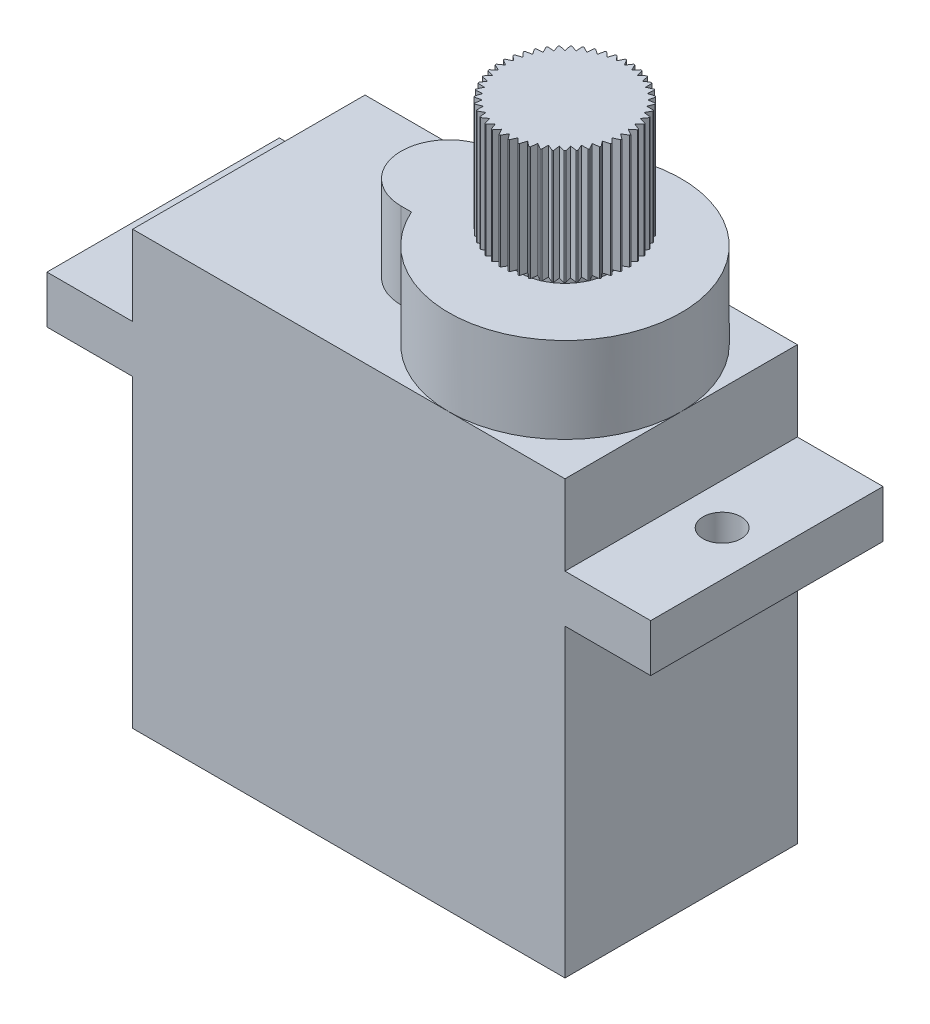
from build123d import *

# Parameters (mm, degrees)
SKETCH2_W                = 22.7
SKETCH2_H                = 12.2
BOSS_EXTRUDE1_DEPTH      = 6.7
BOSS_EXTRUDE1_DEPTH_BACK = 16
SKETCH3_W                = 4.5
SKETCH3_H                = 12.2
SKETCH3_R                = 1
BOSS_EXTRUDE2_DEPTH      = 2.5
BOSS_EXTRUDE3_DEPTH      = 4.5
SKETCH5_R                = 2.425
SKETCH5_R_2              = 0.5
BOSS_EXTRUDE4_DEPTH      = 2.7
BOSS_EXTRUDE5_DEPTH      = 4
BOSS_EXTRUDE5_DEPTH_BACK = 2


with BuildPart() as part:
    # Sketch2 → Boss-Extrude1 (new body, two sides)
    with BuildSketch(Plane(origin=(0, 0, 0), x_dir=(1, 0, 0), z_dir=(0, 1, 0))) as boss_extrude1_sk:
        Rectangle(SKETCH2_W, SKETCH2_H)
    extrude(amount=BOSS_EXTRUDE1_DEPTH)
    extrude(boss_extrude1_sk.sketch, amount=-BOSS_EXTRUDE1_DEPTH_BACK)

    # Sketch3 → Boss-Extrude2 (add)
    with BuildSketch(Plane(origin=(0, 0, 0), x_dir=(1, 0, 0), z_dir=(0, 1, 0))):
        with Locations((13.6, 0)):
            Rectangle(SKETCH3_W, SKETCH3_H)
        with Locations((13.5, 0)):
            Circle(SKETCH3_R, mode=Mode.SUBTRACT)
        with Locations((-13.6, 0)):
            Rectangle(SKETCH3_W, SKETCH3_H)
        with Locations((-13.5, 0)):
            Circle(SKETCH3_R, mode=Mode.SUBTRACT)
    extrude(amount=BOSS_EXTRUDE2_DEPTH)

    # Sketch4 → Boss-Extrude3 (add)
    with BuildSketch(Plane(origin=(0, 6.7, 0), x_dir=(1, 0, 0), z_dir=(0, 1, 0))):
        with BuildLine():
            Line((-0.85, 2.5), (-0.314171097, 2.5))
            ThreePointArc((-0.314171097, 2.5), (11.35, 0), (-0.314171097, -2.5))
            Line((-0.314171097, -2.5), (-0.85, -2.5))
            ThreePointArc((-0.85, -2.5), (-3.35, 0), (-0.85, 2.5))
        make_face()
    extrude(amount=BOSS_EXTRUDE3_DEPTH)


with BuildPart() as body_2:
    # Sketch5 → Boss-Extrude4 (new body)
    with BuildSketch(Plane(origin=(0, 11.2, 0), x_dir=(1, 0, 0), z_dir=(0, 1, 0))):
        with Locations((5.25, 0)):
            Circle(SKETCH5_R)
        with Locations((5.25, 0)):
            Circle(SKETCH5_R_2, mode=Mode.SUBTRACT)
    extrude(amount=BOSS_EXTRUDE4_DEPTH)

    # Sketch6 → Boss-Extrude5 (add, two sides)
    with BuildSketch(Plane(origin=(0, 13.9, 0), x_dir=(1, 0, 0), z_dir=(0, 1, 0))) as boss_extrude5_sk:
        Polygon((5.301910888, 3.074698231), (5.501095267, 3.36131865), (5.562636503, 3.356154096), (5.711264879, 3.040345155), (5.946874795, 3.297859521), (6.007178562, 3.284538404), (6.112387586, 2.951737048), (6.380218576, 3.175550011), (6.438208751, 3.154310046), (6.498120967, 2.810455124), (6.79339358, 2.996572735), (6.848035326, 2.967792951), (6.8615816, 2.619020561), (7.179026689, 2.764121548), (7.229344924, 2.72831552), (7.19628352, 2.380849514), (7.530236271, 2.482344547), (7.575333064, 2.440151234), (7.496253966, 2.100192151), (7.840754983, 2.156270048), (7.879825581, 2.108442391), (7.756139956, 1.78205681), (8.105041611, 1.791716859), (8.137388798, 1.739108344), (7.971303819, 1.432120622), (8.318379953, 1.395190441), (8.343426493, 1.338739867), (8.137905951, 1.056628209), (8.476962983, 0.973766816), (8.49426192, 0.914481546), (8.252973332, 0.662280239), (8.577960781, 0.534966299), (8.587203415, 0.47390428), (8.314452584, 0.256113864), (8.619571041, 0.086619295), (8.620592437, 0.024870181), (8.321246607, -0.15462287), (8.601051226, -0.363273431), (8.593833157, -0.424607728), (8.273234161, -0.562600355), (8.522731822, -0.806683535), (8.507403094, -0.866508501), (8.17127203, -0.960538224), (8.386010441, -1.235698352), (8.362844597, -1.292946409), (8.01717973, -1.341335265), (8.193326879, -1.642662102), (8.162737314, -1.696311659), (7.813707043, -1.698196146), (7.94811958, -2.020312509), (7.910652164, -2.069406186), (7.564484942, -2.024752677), (7.654764273, -2.361910391), (7.611087614, -2.405572111), (7.273960803, -2.315177448), (7.318495891, -2.661359925), (7.269389399, -2.698810545), (6.947319036, -2.564287823), (6.94531515, -2.913317429), (6.891655132, -2.943888641), (6.59038857, -2.767638421), (6.54188147, -3.113286715), (6.484625491, -3.136432974), (6.209538838, -2.921600446), (6.115394135, -3.257699325), (6.055563929, -3.273007586), (5.811566113, -3.023426442), (5.673463821, -3.343978214), (5.612127059, -3.351175301), (5.403572228, -3.071299321), (5.223976785, -3.370583732), (5.162228023, -3.369541212), (4.992837842, -3.064364791), (4.774954134, -3.337041104), (4.713895281, -3.327777581), (4.586692521, -3.002746599), (4.334408688, -3.243948898), (4.275129339, -3.226629681), (4.192383938, -2.887544323), (3.91020199, -3.092968347), (3.853759988, -3.067902497), (3.816948539, -2.72081375), (3.50990402, -2.886793703), (3.457306573, -2.85442852), (3.467085976, -2.50553019), (3.140658103, -2.629104156), (3.092843814, -2.590017199), (3.149039557, -2.245535386), (2.809053443, -2.324498184), (2.766875559, -2.27938696), (2.868484827, -1.945468949), (2.521007532, -1.978411487), (2.485218718, -1.928081006), (2.630428291, -1.610685573), (2.281660556, -1.597019989), (2.252899465, -1.542368401), (2.439118075, -1.247159474), (2.095283668, -1.187129633), (2.074063542, -1.129132196), (2.297968113, -0.861377785), (1.965202767, -0.756054919), (1.95190228, -0.695746599), (2.20949723, -0.460224789), (1.893739151, -0.311488388), (1.88859565, -0.249945389), (2.175284191, -0.050859071), (1.882168089, 0.138636661), (1.88527336, 0.200316104), (2.195939529, 0.359414228), (1.930696068, 0.586287735), (1.941994697, 0.64700295), (2.271094648, 0.763273772), (2.038457104, 1.023476491), (2.057747467, 1.082144014), (2.399408403, 1.153512678), (2.203528199, 1.442401284), (2.230466059, 1.497974192), (2.578591033, 1.523167122), (2.422963655, 1.835586393), (2.457068306, 1.887072985), (2.80544502, 1.865640613), (2.692847642, 2.196015419), (2.733510485, 2.242496916), (3.075922148, 2.174821703), (3.008364073, 2.517256497), (3.054859478, 2.557903437), (3.385195746, 2.445193049), (3.363882551, 2.793577074), (3.415380807, 2.82766411), (3.727746821, 2.671929866), (3.753058839, 3.020046202), (3.808640959, 3.04696505), (4.09746254, 2.850986032), (4.168948077, 3.192622534), (4.227622196, 3.211892826), (4.487745317, 2.979166284), (4.604128713, 3.308226441), (4.66484779, 3.319504299), (4.891630547, 3.054183244), (5.050834937, 3.364794968), (5.112515439, 3.367879139), align=None)
    extrude(amount=BOSS_EXTRUDE5_DEPTH)
    extrude(boss_extrude5_sk.sketch, amount=-BOSS_EXTRUDE5_DEPTH_BACK)


solid = Compound([part.part, body_2.part])
